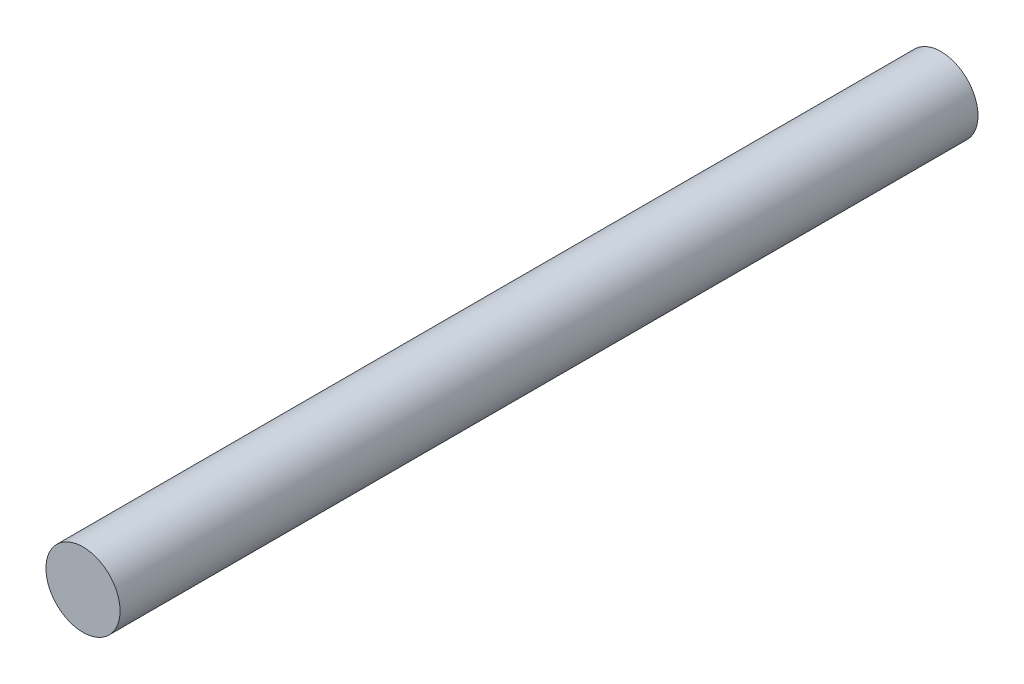
from build123d import *

# Parameters (mm, degrees)
CROQUIS1_R              = 4.75
SALIENTE_EXTRUIR1_DEPTH = 110


with BuildPart() as part:
    # Croquis1 → Saliente-Extruir1 (new body)
    with BuildSketch(Plane.XY):
        Circle(CROQUIS1_R)
    extrude(amount=SALIENTE_EXTRUIR1_DEPTH)


solid = part.part
